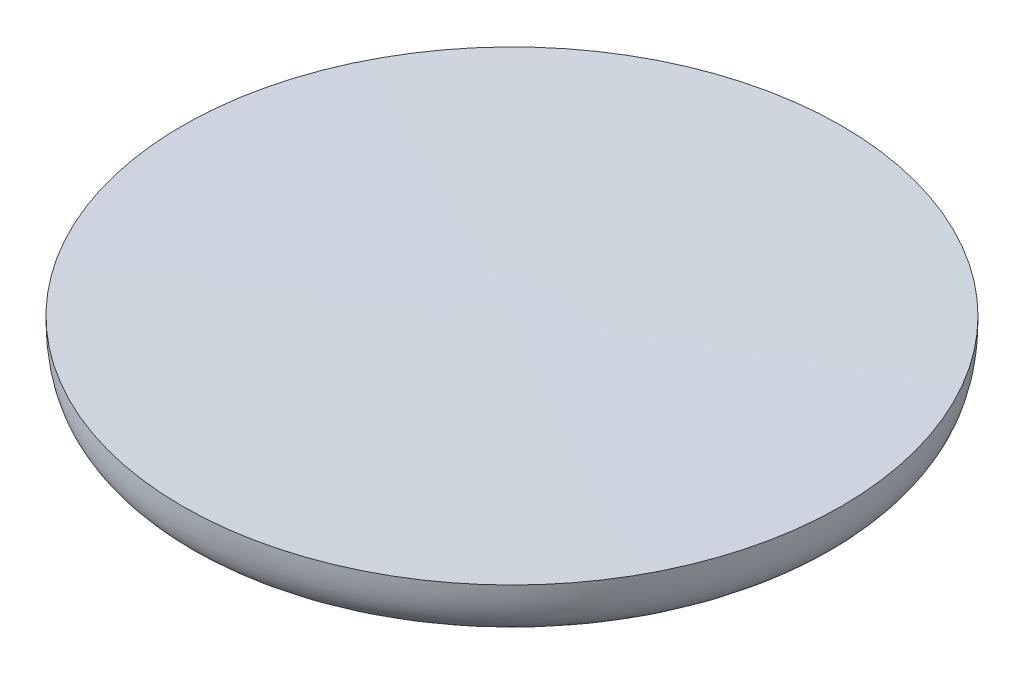
from build123d import *


with BuildPart() as part:
    # Sketch1 → Revolve1 (revolve)
    with BuildSketch(Plane.XY, mode=Mode.PRIVATE) as revolve1_sk:
        with BuildLine():
            Line((0, 0), (0, 24.058090867))
            Line((0, 24.058090867), (124, 25))
            add(Edge.make_bspline(
                [(0, 0), (48.041831914, 0.87952924), (65.297373683, -0.330016453), (120.038778042, 3.958857524), (124, 14.637346781), (124, 25)],
                knots=[0, 0, 0, 0, 0.691991516, 0.860699737, 1, 1, 1, 1], degree=3))
        make_face()
    revolve(revolve1_sk.sketch.rotate(Axis((0, 0, 0), (0, 1, 0)), 270), axis=Axis((0, 0, 0), (0, 1, 0)))  # turned: the seam where the file's is


solid = part.part
